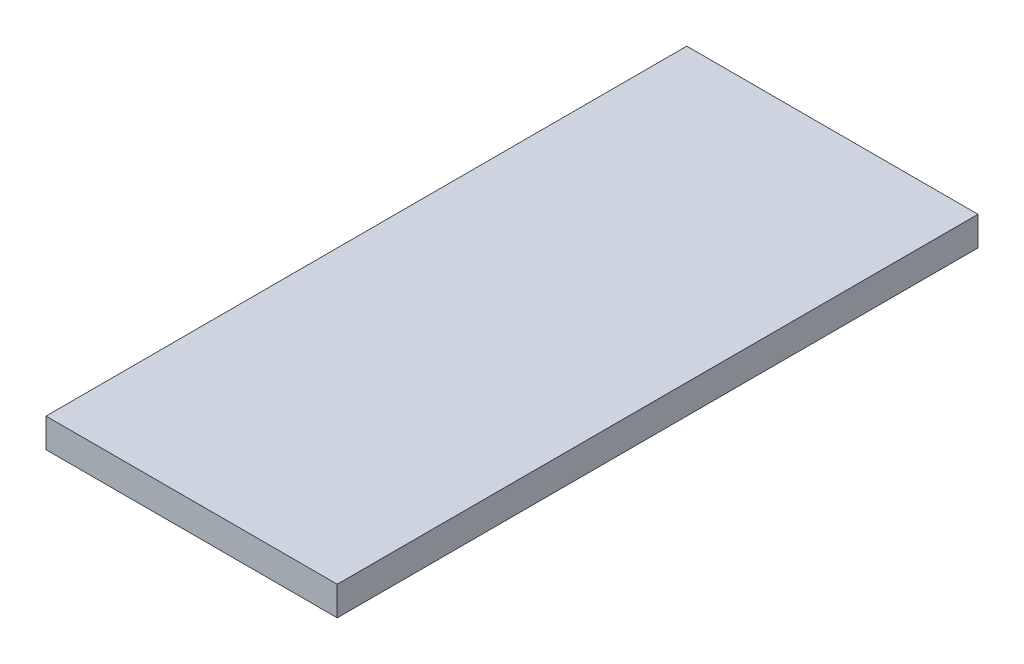
from build123d import *

# Parameters (mm, degrees)
SKETCH2_W           = 50
SKETCH2_H           = 110
BOSS_EXTRUDE1_DEPTH = 5


with BuildPart() as part:
    # Sketch2 → Boss-Extrude1 (new body)
    with BuildSketch(Plane(origin=(0, 0, 0), x_dir=(1, 0, 0), z_dir=(0, 1, 0))):
        with Locations((-30.057803468, -15.657514451)):
            Rectangle(SKETCH2_W, SKETCH2_H)
    extrude(amount=BOSS_EXTRUDE1_DEPTH)


solid = part.part
